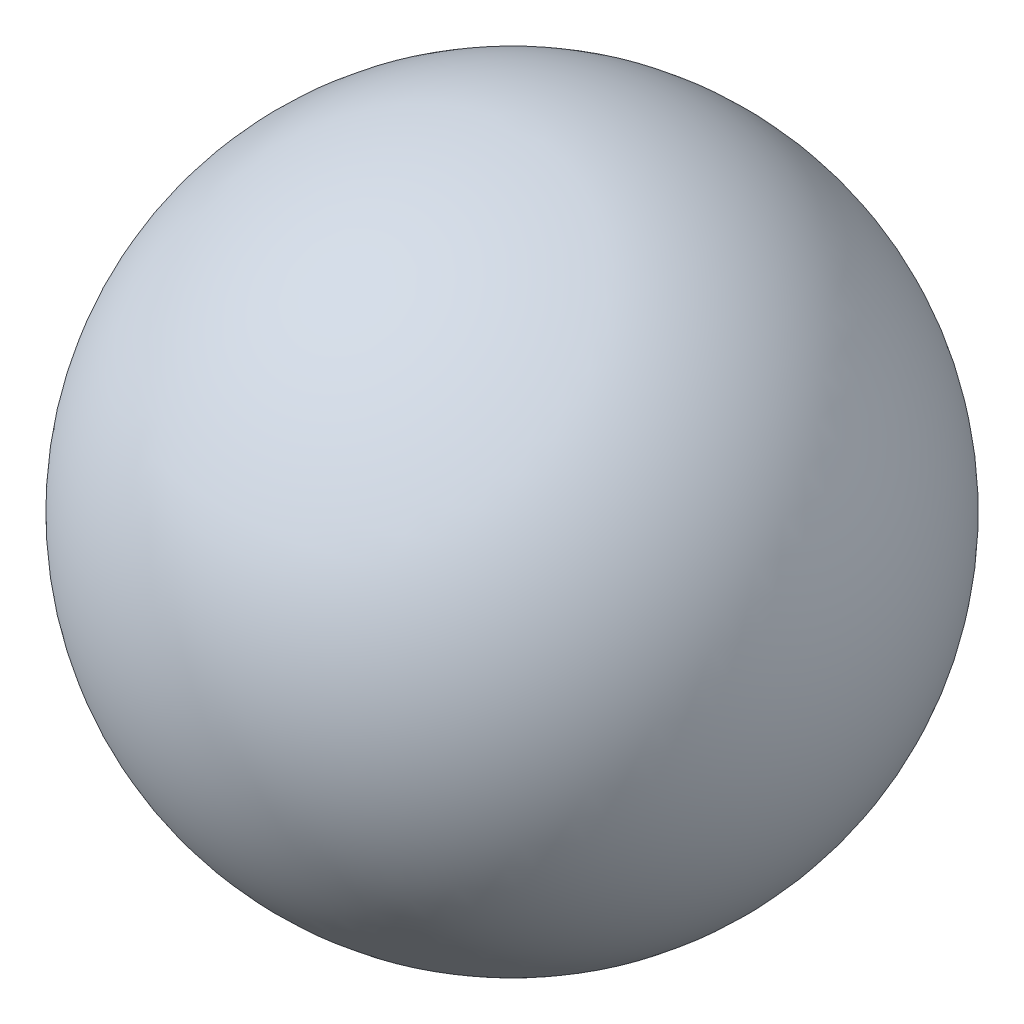
from build123d import *


with BuildPart() as part:
    # Sketch1 → Revolve6 (revolve)
    with BuildSketch(Plane.XY):
        with BuildLine():
            Line((0, 304.8), (0, -304.8))
            ThreePointArc((0, -304.8), (304.8, 0), (0, 304.8))
        make_face()
    revolve(axis=Axis((0, 304.8, 0), (0, -1, 0)))


solid = part.part
